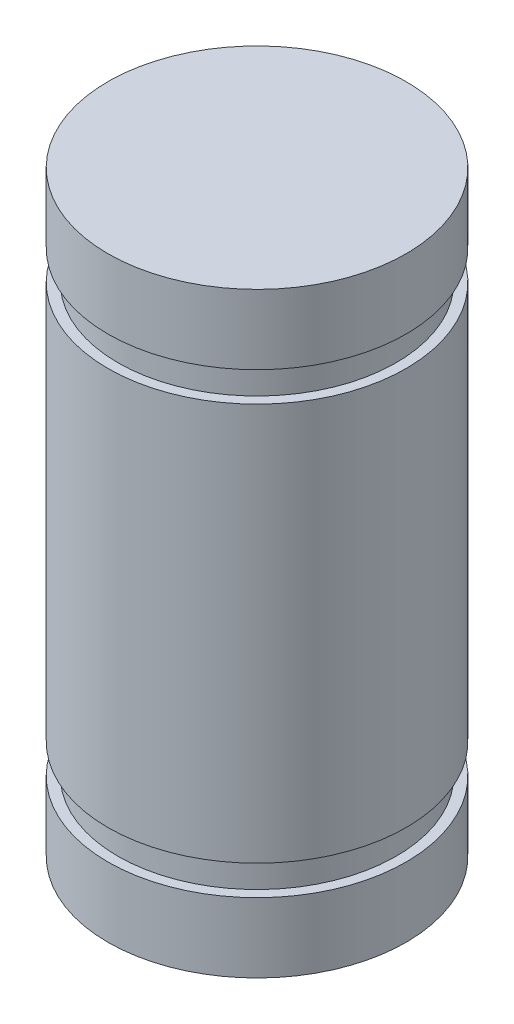
from build123d import *


with BuildPart() as part:
    # 草图1 → 旋转1 (revolve)
    with BuildSketch(Plane.XY):
        Polygon((0, -6), (3, -6), (3, -4.6), (2.8, -4.6), (2.8, -4), (3, -4), (3, 4), (2.8, 4), (2.8, 4.6), (3, 4.6), (3, 6), (0, 6), align=None)
    revolve(axis=Axis((0, 6, 0), (0, -1, 0)))


solid = part.part
